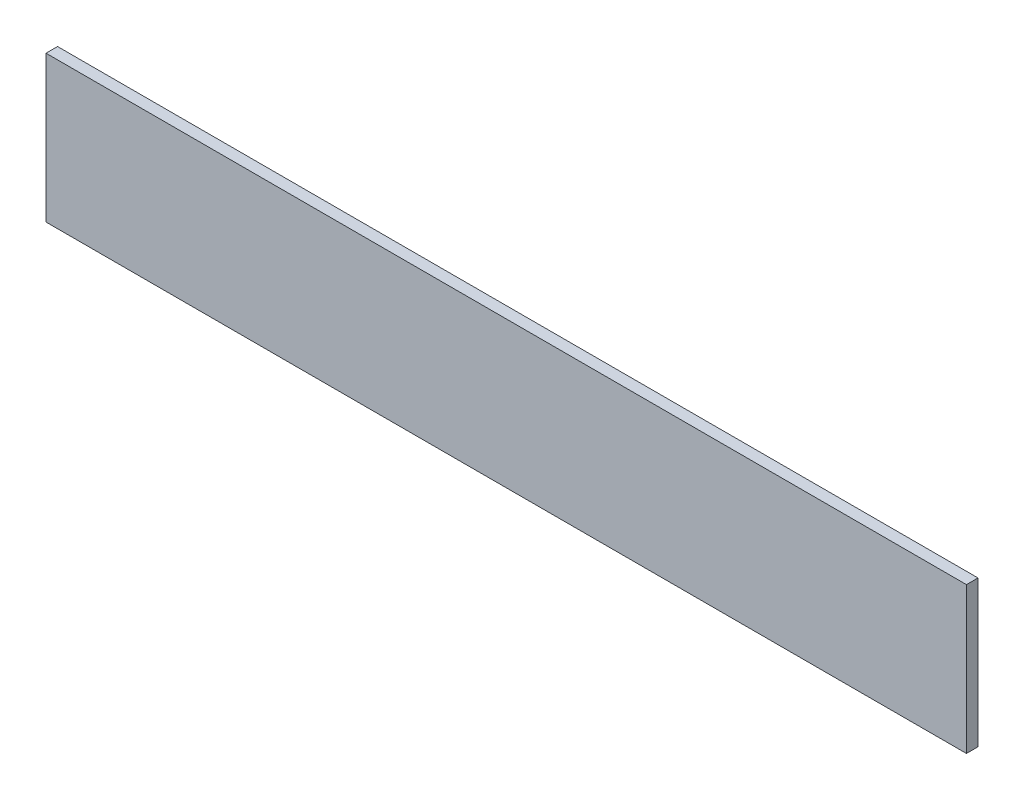
from build123d import *

# Parameters (mm, degrees)
SKETCH1_W           = 892
SKETCH1_H           = 141.732
BOSS_EXTRUDE1_DEPTH = 11.2


with BuildPart() as part:
    # Sketch1 → Boss-Extrude1 (new body)
    with BuildSketch(Plane.XY):
        with Locations((429.89, -61.193115385)):
            Rectangle(SKETCH1_W, SKETCH1_H)
    extrude(amount=-BOSS_EXTRUDE1_DEPTH)


solid = part.part
